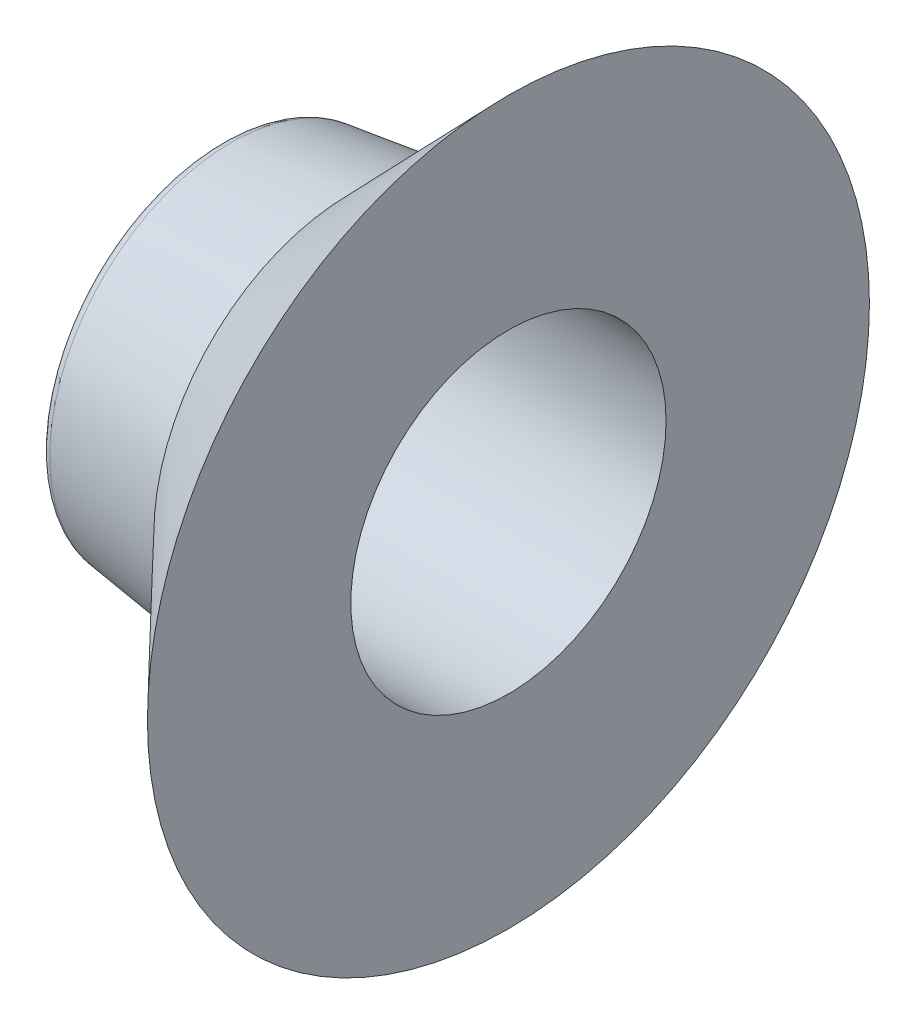
from build123d import *


with BuildPart() as part:
    # Sketch1 → Revolve1 (revolve)
    with BuildSketch(Plane.XY):
        with BuildLine():
            Line((-9.977, -29.2354), (-12.517, -31.877))
            Line((-12.517, -31.877), (-14.44742251, -32.132648849))
            ThreePointArc((-14.44742251, -32.132648849), (-14.6125, -32.334032072), (-14.422412659, -32.512))
            Line((-14.422412659, -32.512), (-9.977, -32.512))
            Line((-9.977, -32.512), (-9.977, -29.2354))
        make_face()
    revolve(axis=Axis((-12.517, -35.052, 0), (-1, 0, 0)))


solid = part.part
